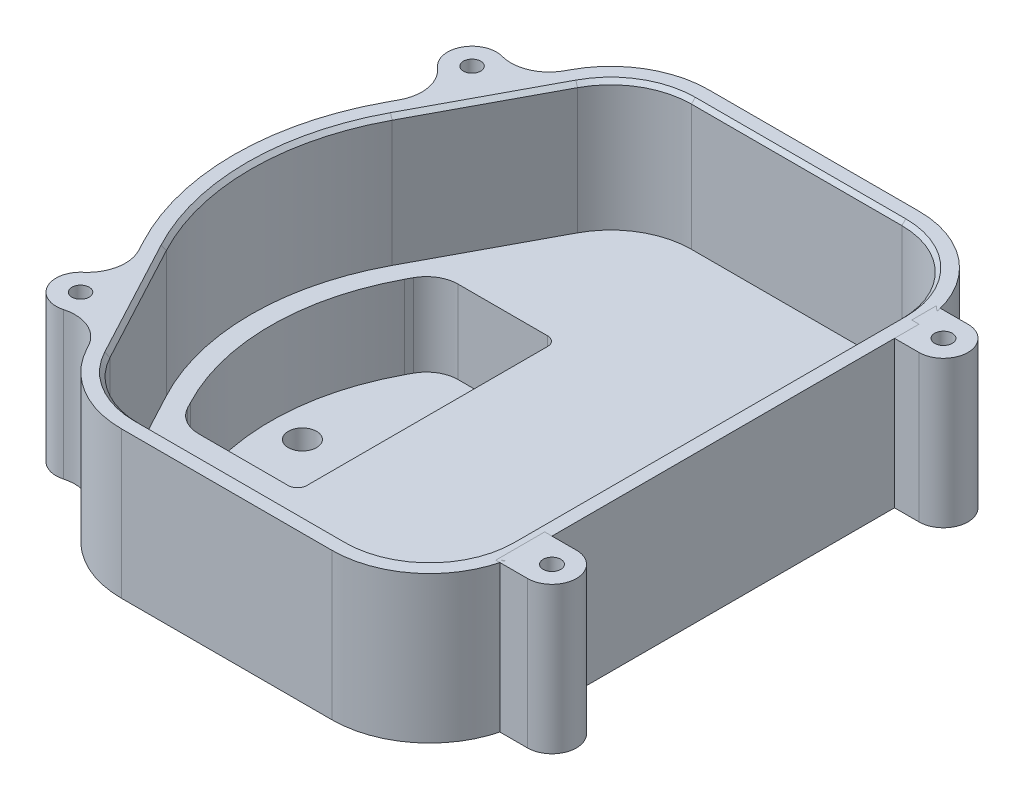
from build123d import *

# Parameters (mm, degrees)
BOSS_EXTRUDE1_DEPTH   = 38.1
FILLET1_R             = 25.4
SHELL1_T              = -4.445
NUB_DEPTH             = 23.368
FILLET2_R             = 12.7
FILLET3_R             = 6.858
CUT_EXTRUDE1_DEPTH    = 21.463
CHAMFER1_SIZE         = 1.016
BOSS_EXTRUDE2_DEPTH   = 38.1
F_8_CLEARANCE_HOLE1_D = 4.4958
SKETCH14_R            = 3.675
CUT_EXTRUDE2_DEPTH    = 62.468
SKETCH18_W            = 17.900644311
SKETCH18_H            = 98.827895465
CUT_EXTRUDE5_DEPTH    = 62.468
SKETCH19_R            = 2.286
BOSS_EXTRUDE4_DEPTH   = 38.1
BOSS_EXTRUDE4_2_DEPTH = 38.1


with BuildPart() as part:
    # Sketch1 → Boss-Extrude1 (new body)
    with BuildSketch(Plane(origin=(0, 0, 0), x_dir=(1, 0, 0), z_dir=(0, 1, 0))):
        with BuildLine():
            Line((-25.4, -76.2), (69.85, -76.2))
            Line((69.85, -76.2), (69.85, 76.2))
            Line((69.85, 76.2), (-25.4, 76.2))
            Line((-25.4, 76.2), (-49.305882353, 31.376470588))
            ThreePointArc((-49.305882353, 31.376470588), (-57.15, 0), (-49.305882353, -31.376470588))
            Line((-49.305882353, -31.376470588), (-25.4, -76.2))
        make_face()
    extrude(amount=BOSS_EXTRUDE1_DEPTH)

    # Fillet1
    fillet1_edges = [part.edges().sort_by_distance(p)[0] for p in [
        (69.85, 19.05, 76.2),
        (-25.4, 19.05, 76.2),
        (-25.4, 19.05, -76.2),
        (69.85, 19.05, -76.2),
    ]]
    fillet(fillet1_edges, radius=FILLET1_R)

    # Shell1
    shell1_openings = [part.faces().sort_by_distance(p)[0] for p in [
        (4.347699305, 38.1, 0),
    ]]
    offset(amount=SHELL1_T, openings=shell1_openings, kind=Kind.INTERSECTION)

    # Sketch13 → nub (add)
    with BuildSketch(Plane.XZ):
        with BuildLine():
            Line((-2.54, 38.1), (-2.54, -38.1))
            Line((-2.54, -38.1), (-40.216666667, -38.1))
            Line((-40.216666667, -38.1), (-44.599411765, -29.882352941))
            ThreePointArc((-44.599411765, -29.882352941), (-52.07, 0), (-44.599411765, 29.882352941))
            Line((-44.599411765, 29.882352941), (-40.216666667, 38.1))
            Line((-40.216666667, 38.1), (-2.54, 38.1))
        make_face()
    extrude(amount=NUB_DEPTH)

    # Fillet2
    fillet2_edges = [part.edges().sort_by_distance(p)[0] for p in [
        (-40.216666667, -11.684, 38.1),
        (-40.216666667, -11.684, -38.1),
    ]]
    fillet(fillet2_edges, radius=FILLET2_R)

    # Fillet3
    fillet3_edges = [part.edges().sort_by_distance(p)[0] for p in [
        (-2.54, -11.684, 38.1),
        (-2.54, -11.684, -38.1),
    ]]
    fillet(fillet3_edges, radius=FILLET3_R)

    # Sketch8 → Cut-Extrude1 (cut)
    with BuildSketch(Plane(origin=(0, 4.445, 0), x_dir=(1, 0, 0), z_dir=(0, 1, 0))):
        with BuildLine():
            Line((-32.596666667, -33.655), (-9.398, -33.655))
            ThreePointArc((-9.398, -33.655), (-7.691751337, -32.948248663), (-6.985, -31.242))
            Line((-6.985, -31.242), (-6.985, 31.242))
            ThreePointArc((-6.985, 31.242), (-7.691751337, 32.948248663), (-9.398, 33.655))
            Line((-9.398, 33.655), (-32.596666667, 33.655))
            ThreePointArc((-32.596666667, 33.655), (-36.843829128, 32.478604102), (-39.880490196, 29.284705882))
            Line((-39.880490196, 29.284705882), (-40.677352941, 27.790588235))
            ThreePointArc((-40.677352941, 27.790588235), (-47.625, 0), (-40.677352941, -27.790588235))
            Line((-40.677352941, -27.790588235), (-39.880490196, -29.284705882))
            ThreePointArc((-39.880490196, -29.284705882), (-36.843829128, -32.478604102), (-32.596666667, -33.655))
        make_face()
    extrude(amount=-CUT_EXTRUDE1_DEPTH, mode=Mode.SUBTRACT)

    # Chamfer1
    chamfer1_edges = [part.edges().sort_by_distance(p)[0] for p in [
        (-37.016764706, 38.1, 44.972941176),
        (-20.941258555, 38.1, 68.768764258),
        (17.145, 38.1, 71.755),
        (59.2674226, 38.1, 65.6174226),
        (65.405, 38.1, 0),
        (59.2674226, 38.1, -65.6174226),
        (17.145, 38.1, -71.755),
        (-20.941258555, 38.1, -68.768764258),
        (-37.016764706, 38.1, -44.972941176),
        (-52.705, 38.1, 0),
    ]]
    chamfer(chamfer1_edges, length=CHAMFER1_SIZE)

    # Sketch10 → Boss-Extrude2 (add)
    with BuildSketch(Plane(origin=(0, 38.1, 0), x_dir=(1, 0, 0), z_dir=(0, 1, 0))):
        with BuildLine():
            Line((69.85, 47.625), (69.85, 15.875))
            ThreePointArc((69.85, 15.875), (72.024192281, 22.073146175), (77.593902439, 25.554878049))
            ThreePointArc((77.593902439, 25.554878049), (82.55, 31.75), (77.593902439, 37.945121951))
            ThreePointArc((77.593902439, 37.945121951), (72.024192281, 41.426853825), (69.85, 47.625))
        make_face()
        with BuildLine():
            Line((69.85, -47.625), (69.85, -15.875))
            ThreePointArc((69.85, -15.875), (72.024192281, -22.073146175), (77.593902439, -25.554878049))
            ThreePointArc((77.593902439, -25.554878049), (82.55, -31.75), (77.593902439, -37.945121951))
            ThreePointArc((77.593902439, -37.945121951), (72.024192281, -41.426853825), (69.85, -47.625))
        make_face()
        with BuildLine():
            Line((-33.069803922, 61.819117647), (-48.010980392, 33.804411765))
            ThreePointArc((-48.010980392, 33.804411765), (-47.012610676, 40.296513581), (-50.288598757, 45.989670014))
            ThreePointArc((-50.288598757, 45.989670014), (-51.74627451, 53.788235294), (-44.457895744, 56.922238164))
            ThreePointArc((-44.457895744, 56.922238164), (-37.904983546, 57.373314449), (-33.069803922, 61.819117647))
        make_face()
        with BuildLine():
            Line((-33.069803922, -61.819117647), (-48.010980392, -33.804411765))
            ThreePointArc((-48.010980392, -33.804411765), (-47.012610676, -40.296513581), (-50.288598757, -45.989670014))
            ThreePointArc((-50.288598757, -45.989670014), (-51.74627451, -53.788235294), (-44.457895744, -56.922238164))
            ThreePointArc((-44.457895744, -56.922238164), (-37.904983546, -57.373314449), (-33.069803922, -61.819117647))
        make_face()
    extrude(amount=-BOSS_EXTRUDE2_DEPTH)

    # #8 Clearance Hole1 (through all)
    with Locations(Plane(origin=(0, 38.1, 0), x_dir=(-1, 0, 0), z_dir=(0, 1, 0))):
        with Locations((46.143333333, -50.8), (46.143333333, 50.8), (-76.2, 31.75), (-76.2, -31.75)):
            Hole(F_8_CLEARANCE_HOLE1_D / 2)

    # Sketch14 → Cut-Extrude2 (cut, through all)
    with BuildSketch(Plane.XZ.offset(23.368)):
        with Locations((-16.51, 22.86)):
            Circle(SKETCH14_R)
        with Locations((-16.51, 0)):
            Circle(SKETCH14_R)
        with Locations((-16.51, -22.86)):
            Circle(SKETCH14_R)
        with Locations((-39.37, 0)):
            Circle(SKETCH14_R)
    extrude(amount=-CUT_EXTRUDE2_DEPTH, mode=Mode.SUBTRACT)

    # Sketch18 → Cut-Extrude5 (cut, through all)
    with BuildSketch(Plane(origin=(0, 38.1, 0), x_dir=(1, 0, 0), z_dir=(0, 1, 0))):
        with Locations((78.800322155, -1.788947733)):
            Rectangle(SKETCH18_W, SKETCH18_H)
    extrude(amount=-CUT_EXTRUDE5_DEPTH, mode=Mode.SUBTRACT)


with BuildPart() as body_2:
    # Sketch19 → Boss-Extrude4 (new body)
    with BuildSketch(Plane(origin=(0, 38.1, 0), x_dir=(1, 0, 0), z_dir=(0, 1, 0))):
        with BuildLine():
            Line((76.2, 57.15), (67.964574811, 57.15))
            Line((67.964574811, 57.15), (67.964574811, 44.45))
            Line((67.964574811, 44.45), (76.2, 44.45))
            ThreePointArc((76.2, 44.45), (82.55, 50.8), (76.2, 57.15))
        make_face()
        with Locations((76.2, 50.8)):
            Circle(SKETCH19_R, mode=Mode.SUBTRACT)
    extrude(amount=-BOSS_EXTRUDE4_DEPTH)


with BuildPart() as body_3:
    # Sketch19 → Boss-Extrude4 2 (new body)
    with BuildSketch(Plane(origin=(0, 38.1, 0), x_dir=(1, 0, 0), z_dir=(0, 1, 0))):
        with BuildLine():
            Line((67.964574811, -44.45), (76.2, -44.45))
            ThreePointArc((76.2, -44.45), (82.55, -50.8), (76.2, -57.15))
            Line((76.2, -57.15), (67.964574811, -57.15))
            Line((67.964574811, -57.15), (67.964574811, -44.45))
        make_face()
        with Locations((76.2, -50.8)):
            Circle(SKETCH19_R, mode=Mode.SUBTRACT)
    extrude(amount=-BOSS_EXTRUDE4_2_DEPTH)


solid = Compound([part.part, body_2.part, body_3.part])
